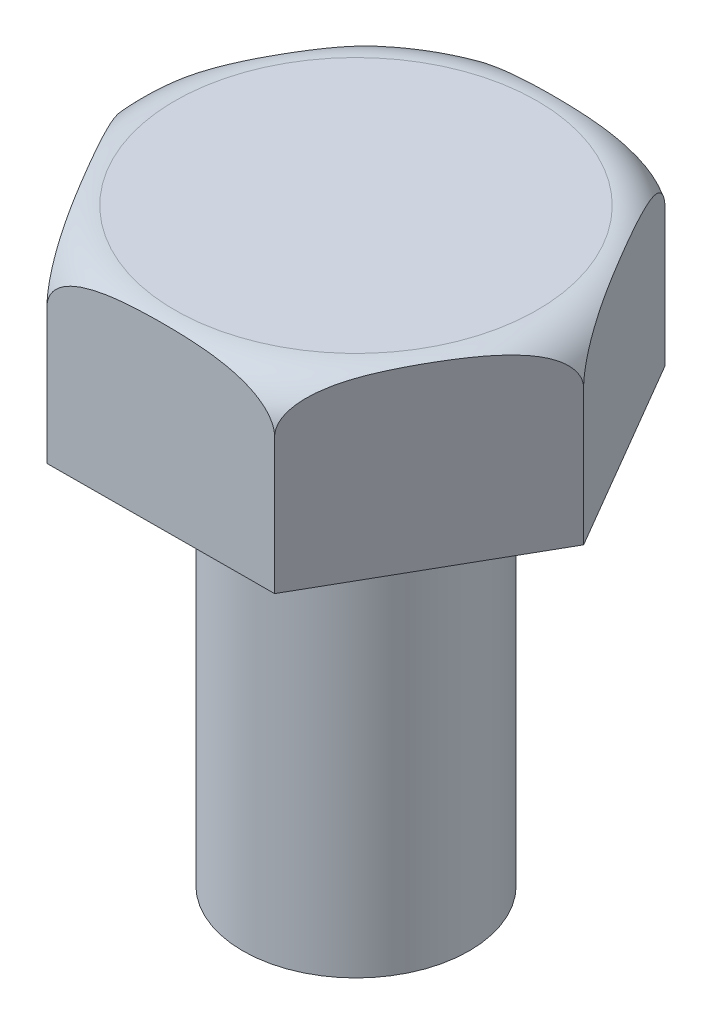
from build123d import *

# Parameters (mm, degrees)
SKETCH1_R           = 5
BOSS_EXTRUDE1_DEPTH = 6.5
SKETCH2_R           = 5
SKETCH2_R_2         = 2.5
CUT_EXTRUDE1_DEPTH  = 9
CUT_EXTRUDE2_DEPTH  = 4


with BuildPart() as part:
    # Sketch1 → Boss-Extrude1 (new body, symmetric)
    with BuildSketch(Plane(origin=(0, 0, 0), x_dir=(1, 0, 0), z_dir=(0, 1, 0))):
        Circle(SKETCH1_R)
    extrude(amount=BOSS_EXTRUDE1_DEPTH, both=True)

    # Sketch2 → Cut-Extrude1 (cut)
    with BuildSketch(Plane.XZ.offset(6.5)):
        Circle(SKETCH2_R)
        Circle(SKETCH2_R_2, mode=Mode.SUBTRACT)
    extrude(amount=-CUT_EXTRUDE1_DEPTH, mode=Mode.SUBTRACT)

    # Sketch4 → Cut-Extrude2 (cut)
    with BuildSketch(Plane(origin=(0, 6.5, 0), x_dir=(1, 0, 0), z_dir=(0, 1, 0))):
        with BuildLine():
            Line((-4.999938781, -0.024742442), (-2.521396974, 4.317702781))
            ThreePointArc((-2.521396974, 4.317702781), (-4.342445223, 2.478541807), (-4.999938781, -0.024742442))
        make_face()
        with BuildLine():
            Line((-2.478541807, -4.342445223), (-4.999938781, -0.024742442))
            ThreePointArc((-4.999938781, -0.024742442), (-4.317702781, -2.521396974), (-2.478541807, -4.342445223))
        make_face()
        with BuildLine():
            ThreePointArc((-2.478541807, -4.342445223), (0.024742442, -4.999938781), (2.521396974, -4.317702781))
            Line((2.521396974, -4.317702781), (-2.478541807, -4.342445223))
        make_face()
        with BuildLine():
            ThreePointArc((5, 0), (4.999984695, 0.012371259), (4.999938781, 0.024742442))
            Line((4.999938781, 0.024742442), (2.521396974, -4.317702781))
            ThreePointArc((2.521396974, -4.317702781), (4.336299394, -2.489278523), (5, 0))
        make_face()
        with BuildLine():
            ThreePointArc((4.999938781, 0.024742442), (4.317702781, 2.521396974), (2.478541807, 4.342445223))
            Line((2.478541807, 4.342445223), (4.999938781, 0.024742442))
        make_face()
        with BuildLine():
            Line((-2.521396974, 4.317702781), (2.478541807, 4.342445223))
            ThreePointArc((2.478541807, 4.342445223), (-0.024742442, 4.999938781), (-2.521396974, 4.317702781))
        make_face()
    extrude(amount=-CUT_EXTRUDE2_DEPTH, mode=Mode.SUBTRACT)

    # Sketch5 → Cut-Revolve1 (revolve, cut)
    with BuildSketch(Plane.XY):
        with BuildLine():
            Line((-3.722260503, 6.5), (-3.722260503, 8.060451161))
            Line((-3.722260503, 8.060451161), (-6.740732256, 6.10732238))
            Line((-6.740732256, 6.10732238), (-4.999938781, 5.059459129))
            Line((-4.999938781, 5.059459129), (-4.999938781, 5.5))
            ThreePointArc((-4.999938781, 5.5), (-4.707045562, 6.207106781), (-3.999938781, 6.5))
            Line((-3.999938781, 6.5), (-3.722260503, 6.5))
        make_face()
    revolve(axis=Axis((0, 0, 0), (0, 1, 0)), mode=Mode.SUBTRACT)


solid = part.part
